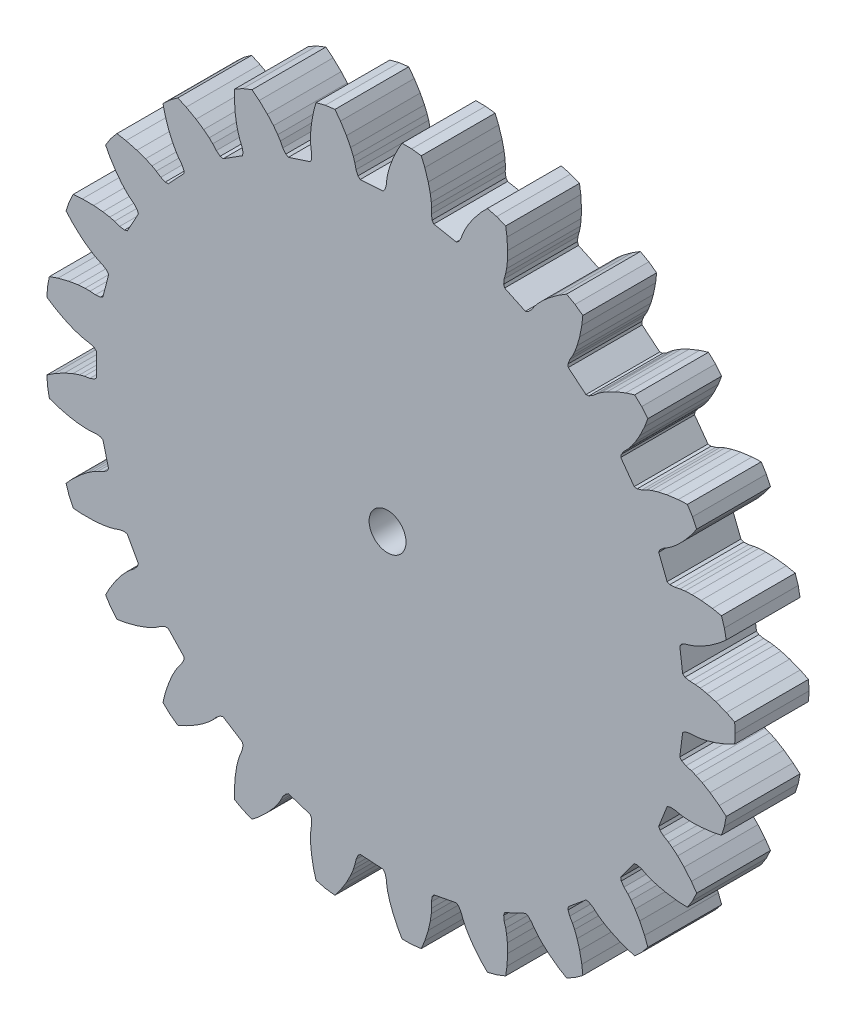
from build123d import *

# Parameters (mm, degrees)
MODEL_R             = 1.5875
BOSS_EXTRUDE1_DEPTH = 6.35


with BuildPart() as part:
    # Model → Boss-Extrude1 (new body)
    with BuildSketch(Plane.XY):
        Polygon((28.724078901, -8.263137844), (28.98062214, -7.473578941), (29.136184489, -6.658092552), (28.534273156, -6.144343716), (27.744510482, -5.577223626), (27.066883431, -5.171965759), (26.521840963, -4.905167788), (26.126650882, -4.751234836), (25.675747676, -4.617827678), (25.303834334, -4.430734433), (25.141153364, -4.229322014), (25.388043562, -2.274984866), (25.595702841, -2.1203573), (26.00246004, -2.03163302), (26.472374303, -2.014552161), (26.89343033, -1.963735072), (27.487699244, -1.8408656), (28.244820928, -1.616858649), (29.150808787, -1.26396167), (29.861574108, -0.91604246), (29.913702255, -0.087489292), (29.861574108, 0.741063875), (29.150808787, 1.088983086), (28.244820928, 1.441880065), (27.487699244, 1.665887016), (26.89343033, 1.788756487), (26.472374303, 1.839573576), (26.00246004, 1.856654436), (25.595702841, 1.945378715), (25.388043562, 2.100006281), (25.141153364, 4.054343429), (25.303834334, 4.255755849), (25.675747676, 4.442849093), (26.126650882, 4.576256252), (26.521840963, 4.730189204), (27.066883431, 4.996987175), (27.744510482, 5.402245041), (28.534273156, 5.969365131), (29.136184489, 6.483113968), (28.98062214, 7.298600357), (28.724078901, 8.08815926), (27.94911959, 8.248387801), (26.983833096, 8.364887854), (26.194789519, 8.393568708), (25.58863426, 8.364789341), (25.168168787, 8.309297541), (24.708769907, 8.208978849), (24.292726903, 8.193759291), (24.05313731, 8.291886184), (23.327979737, 10.123425142), (23.435460553, 10.358966931), (23.749161356, 10.632673385), (24.152721597, 10.87402438), (24.497214486, 11.121401022), (24.958783486, 11.515363594), (25.514338104, 12.076408534), (26.1382519, 12.822117494), (26.593488941, 13.469415227), (26.240010652, 14.220594829), (25.795171876, 14.921548578), (25.004712119, 14.884018701), (24.04077949, 14.756801701), (23.26939253, 14.588354336), (22.689437891, 14.409734442), (22.295982363, 14.251420509), (21.875964588, 14.040005657), (21.47677729, 13.921798561), (21.220311678, 13.957259109), (20.062451048, 15.550917547), (20.107978295, 15.80578875), (20.343755583, 16.14891043), (20.674615685, 16.48304029), (20.946765628, 16.808317037), (21.295859082, 17.304690093), (21.694433726, 17.98626959), (22.113295846, 18.863711784), (22.393254378, 19.603886317), (21.864070489, 20.243559754), (21.258887033, 20.811864847), (20.502594323, 20.578934693), (19.600582992, 20.215994152), (18.895321727, 19.861002734), (18.378008391, 19.543765659), (18.036285066, 19.292577038), (17.682039658, 18.98335), (17.324790472, 18.769582753), (17.067563519, 18.740148839), (15.549752473, 19.995791337), (15.530465507, 20.253977459), (15.673504526, 20.644954767), (15.910875333, 21.050868884), (16.093582147, 21.433607403), (16.308265228, 22.001201998), (16.524815989, 22.760489906), (16.712307786, 23.714532412), (16.799396985, 24.501075857), (16.127758066, 24.989050095), (15.400255831, 25.388997833), (14.725650822, 24.975303259), (13.942237477, 24.399444067), (13.347416067, 23.880214013), (12.925248733, 23.444292929), (12.656729345, 23.116012725), (12.390514844, 22.728403372), (12.097651051, 22.432507757), (11.855825273, 22.340028821), (10.07343346, 23.178758744), (9.990544153, 23.424037), (10.031857235, 23.838303395), (10.160823866, 24.290496693), (10.24260741, 24.706648115), (10.309390792, 25.309800193), (10.330310989, 26.099087659), (10.274651662, 27.069784479), (10.163399393, 27.853275419), (9.391506988, 28.158889242), (8.587397616, 28.365349437), (8.03686822, 27.796884396), (7.421277603, 27.044289903), (6.974270866, 26.393446346), (6.67377586, 25.866231778), (6.495332469, 25.481487044), (6.333876113, 25.039850298), (6.123799422, 24.680418524), (5.912569621, 24.530705358), (3.977591275, 24.899822219), (3.836307865, 25.116780876), (3.773299159, 25.528306475), (3.785758165, 25.998365986), (3.761479679, 26.421781986), (3.676167116, 27.022593285), (3.500142255, 27.792286475), (3.204829086, 28.718645158), (2.902225738, 29.449853974), (2.078580685, 29.553904542), (1.248389324, 29.553904542), (0.856527329, 28.866387782), (0.447439263, 27.984346268), (0.176334275, 27.242784103), (0.016392804, 26.657402881), (-0.060762335, 26.240368544), (-0.107315651, 25.772454065), (-0.221405349, 25.372070552), (-0.388766826, 25.174530186), (-2.3547499, 25.050841015), (-2.545550056, 25.225847761), (-2.708921483, 25.6087749), (-2.813752946, 26.067165056), (-2.942567956, 26.471240849), (-3.174615962, 27.031960184), (-3.536525591, 27.733696444), (-4.05293699, 28.557510468), (-4.527877735, 29.190492622), (-5.351522788, 29.086442054), (-6.155632161, 28.879981859), (-6.364204625, 28.116612586), (-6.541085632, 27.160545963), (-6.619254348, 26.374860269), (-6.628592573, 25.768094048), (-6.59961152, 25.344973908), (-6.528336678, 24.880182485), (-6.539270708, 24.464004802), (-6.652247926, 24.231049423), (-8.52570578, 23.622326066), (-8.754034006, 23.744384584), (-9.007502926, 24.07465254), (-9.223037912, 24.492571002), (-9.448295525, 24.851917021), (-9.812498545, 25.337312335), (-10.337552828, 25.926998995), (-11.04261443, 26.596505093), (-11.660050299, 27.091487989), (-12.431942705, 26.785874166), (-13.15944494, 26.385926428), (-13.171622498, 25.594669942), (-13.105182363, 24.624651393), (-12.985503178, 23.84420969), (-12.843651403, 23.254183823), (-12.710355143, 22.851564076), (-12.525730604, 22.419100262), (-12.432821941, 22.013278384), (-12.484316124, 21.759545435), (-14.147532512, 20.704036219), (-14.399042106, 20.765477124), (-14.726682135, 21.022333948), (-15.039377788, 21.373521361), (-15.34692424, 21.665558574), (-15.820398058, 22.045130693), (-16.475605904, 22.485715572), (-17.325016096, 22.958846215), (-18.046151322, 23.284728256), (-18.717790241, 22.796754018), (-19.322973697, 22.228448925), (-19.137991189, 21.459022781), (-18.832404589, 20.536002138), (-18.522397387, 19.80984245), (-18.23826868, 19.273630432), (-18.009032708, 18.916809157), (-17.722659112, 18.543846244), (-17.531745547, 18.173879452), (-17.518521128, 17.915311907), (-18.866990047, 16.479338358), (-19.125877736, 16.476301092), (-19.507102045, 16.643607524), (-19.897310548, 16.905997492), (-20.267821564, 17.112376127), (-20.820816079, 17.36227514), (-21.56500837, 17.626074669), (-22.505395584, 17.873101318), (-23.284918589, 18.009406138), (-23.814102478, 17.369732701), (-24.258941254, 16.668778952), (-23.888421811, 15.969529024), (-23.362889876, 15.151503069), (-22.88203355, 14.525252678), (-22.473480762, 14.076546684), (-22.162708816, 13.787944273), (-21.792580069, 13.497916893), (-21.515657406, 13.187051561), (-21.438545322, 12.93989617), (-22.38753751, 11.213685788), (-22.637536429, 11.146361192), (-23.048391294, 11.213604755), (-23.49159441, 11.370710352), (-23.901789421, 11.478462879), (-24.499557953, 11.582986711), (-25.28597435, 11.653425397), (-26.2582506, 11.658826459), (-27.047181087, 11.596989524), (-27.400659376, 10.845809922), (-27.657202615, 10.056251019), (-27.124427336, 9.471113753), (-26.411971171, 8.809482064), (-25.790479691, 8.322490587), (-25.283173697, 7.989484463), (-24.910392723, 7.787234868), (-24.479765374, 7.598366508), (-24.134233681, 7.366135447), (-23.998079169, 7.145921893), (-24.487965958, 5.237938824), (-24.713367755, 5.110557152), (-25.128037652, 5.073512685), (-25.596387301, 5.115462387), (-26.020492245, 5.117818319), (-26.6254748, 5.070399355), (-27.404701868, 4.943051274), (-28.347775462, 4.706487381), (-29.096542026, 4.450394134), (-29.252104374, 3.634907745), (-29.304232521, 2.806354577), (-28.642677636, 2.372096298), (-27.788063482, 1.908431629), (-27.064987444, 1.591298531), (-26.490804146, 1.394916277), (-26.079437342, 1.291727582), (-25.615369292, 1.215885536), (-25.222939596, 1.076880679), (-25.036297745, 0.897445789), (-25.036297745, -1.072424374), (-25.222939596, -1.251859264), (-25.615369292, -1.390864121), (-26.079437342, -1.466706167), (-26.490804146, -1.569894861), (-27.064987444, -1.766277115), (-27.788063482, -2.083410213), (-28.642677636, -2.547074882), (-29.304232521, -2.981333162), (-29.252104374, -3.809886329), (-29.096542026, -4.625372718), (-28.347775462, -4.881465966), (-27.404701868, -5.118029859), (-26.6254748, -5.245377939), (-26.020492245, -5.292796904), (-25.596387301, -5.290440971), (-25.128037652, -5.248491269), (-24.713367755, -5.285535736), (-24.487965958, -5.412917409), (-23.998079169, -7.320900478), (-24.134233681, -7.541114032), (-24.479765374, -7.773345093), (-24.910392723, -7.962213452), (-25.283173697, -8.164463048), (-25.790479691, -8.497469172), (-26.411971171, -8.984460649), (-27.124427336, -9.646092337), (-27.657202615, -10.231229604), (-27.400659376, -11.020788507), (-27.047181087, -11.771968109), (-26.2582506, -11.833805044), (-25.28597435, -11.828403981), (-24.499557953, -11.757965296), (-23.901789421, -11.653441463), (-23.49159441, -11.545688936), (-23.048391294, -11.38858334), (-22.637536429, -11.321339777), (-22.38753751, -11.388664372), (-21.438545322, -13.114874755), (-21.515657406, -13.362030145), (-21.792580069, -13.672895478), (-22.162708816, -13.962922857), (-22.473480762, -14.251525268), (-22.88203355, -14.700231263), (-23.362889876, -15.326481653), (-23.888421811, -16.144507609), (-24.258941254, -16.843757536), (-23.814102478, -17.544711285), (-23.284918589, -18.184384723), (-22.505395584, -18.048079903), (-21.56500837, -17.801053254), (-20.820816079, -17.537253724), (-20.267821564, -17.287354711), (-19.897310548, -17.080976077), (-19.507102045, -16.818586109), (-19.125877736, -16.651279676), (-18.866990047, -16.654316943), (-17.518521128, -18.090290491), (-17.531745547, -18.348858036), (-17.722659112, -18.718824829), (-18.009032708, -19.091787741), (-18.23826868, -19.448609017), (-18.522397387, -19.984821034), (-18.832404589, -20.710980722), (-19.137991189, -21.634001366), (-19.322973697, -22.40342751), (-18.717790241, -22.971732603), (-18.046151322, -23.459706841), (-17.325016096, -23.1338248), (-16.475605904, -22.660694157), (-15.820398058, -22.220109278), (-15.34692424, -21.840537158), (-15.039377788, -21.548499945), (-14.726682135, -21.197312532), (-14.399042106, -20.940455708), (-14.147532512, -20.879014803), (-12.484316124, -21.934524019), (-12.432821941, -22.188256968), (-12.525730604, -22.594078846), (-12.710355143, -23.026542661), (-12.843651403, -23.429162408), (-12.985503178, -24.019188275), (-13.105182363, -24.799629977), (-13.171622498, -25.769648527), (-13.15944494, -26.560905012), (-12.431942705, -26.960852751), (-11.660050299, -27.266466574), (-11.04261443, -26.771483678), (-10.337552828, -26.10197758), (-9.812498545, -25.512290919), (-9.448295525, -25.026895606), (-9.223037912, -24.667549586), (-9.007502926, -24.249631125), (-8.754034006, -23.919363169), (-8.52570578, -23.79730465), (-6.652247926, -24.406028007), (-6.539270708, -24.638983387), (-6.528336678, -25.055161069), (-6.59961152, -25.519952493), (-6.628592573, -25.943072632), (-6.619254348, -26.549838854), (-6.541085632, -27.335524548), (-6.364204625, -28.291591171), (-6.155632161, -29.054960443), (-5.351522788, -29.261420639), (-4.527877735, -29.365471207), (-4.05293699, -28.732489052), (-3.536525591, -27.908675029), (-3.174615962, -27.206938769), (-2.942567956, -26.646219434), (-2.813752946, -26.24214364), (-2.708921483, -25.783753484), (-2.545550056, -25.400826346), (-2.3547499, -25.2258196), (-0.388766826, -25.349508771), (-0.221405349, -25.547049137), (-0.107315651, -25.947432649), (-0.060762335, -26.415347128), (0.016392804, -26.832381465), (0.176334275, -27.417762688), (0.447439263, -28.159324852), (0.856527329, -29.041366366), (1.248389324, -29.728883127), (2.078580685, -29.728883127), (2.902225738, -29.624832559), (3.204829086, -28.893623743), (3.500142255, -27.967265059), (3.676167116, -27.197571869), (3.761479679, -26.596760571), (3.785758165, -26.173344571), (3.773299159, -25.70328506), (3.836307865, -25.29175946), (3.977591275, -25.074800804), (5.912569621, -24.705683943), (6.123799422, -24.855397108), (6.333876113, -25.214828882), (6.495332469, -25.656465629), (6.67377586, -26.041210362), (6.974270866, -26.568424931), (7.421277603, -27.219268487), (8.03686822, -27.97186298), (8.587397616, -28.540328022), (9.391506988, -28.333867826), (10.163399393, -28.028254003), (10.274651662, -27.244763064), (10.330310989, -26.274066243), (10.309390792, -25.484778778), (10.24260741, -24.881626699), (10.160823866, -24.465475278), (10.031857235, -24.013281979), (9.990544153, -23.599015585), (10.07343346, -23.353737328), (11.855825273, -22.515007406), (12.097651051, -22.607486342), (12.390514844, -22.903381957), (12.656729345, -23.29099131), (12.925248733, -23.619271513), (13.347416067, -24.055192598), (13.942237477, -24.574422652), (14.725650822, -25.150281844), (15.400255831, -25.563976418), (16.127758066, -25.16402868), (16.799396985, -24.676054441), (16.712307786, -23.889510997), (16.524815989, -22.93546849), (16.308265228, -22.176180583), (16.093582147, -21.608585988), (15.910875333, -21.225847469), (15.673504526, -20.819933351), (15.530465507, -20.428956043), (15.549752473, -20.170769922), (17.067563519, -18.915127423), (17.324790472, -18.944561338), (17.682039658, -19.158328585), (18.036285066, -19.467555623), (18.378008391, -19.718744244), (18.895321727, -20.035981319), (19.600582992, -20.390972737), (20.502594323, -20.753913277), (21.258887033, -20.986843431), (21.864070489, -20.418538338), (22.393254378, -19.778864901), (22.113295846, -19.038690368), (21.694433726, -18.161248175), (21.295859082, -17.479668678), (20.946765628, -16.983295622), (20.674615685, -16.658018874), (20.343755583, -16.323889014), (20.107978295, -15.980767335), (20.062451048, -15.725896132), (21.220311678, -14.132237694), (21.47677729, -14.096777146), (21.875964588, -14.214984242), (22.295982363, -14.426399093), (22.689437891, -14.584713026), (23.26939253, -14.763332921), (24.04077949, -14.931780286), (25.004712119, -15.058997285), (25.795171876, -15.096527162), (26.240010652, -14.395573413), (26.593488941, -13.644393812), (26.1382519, -12.997096078), (25.514338104, -12.251387119), (24.958783486, -11.690342178), (24.497214486, -11.296379606), (24.152721597, -11.049002964), (23.749161356, -10.80765197), (23.435460553, -10.533945516), (23.327979737, -10.298403726), (24.05313731, -8.466864769), (24.292726903, -8.368737875), (24.708769907, -8.383957434), (25.168168787, -8.484276126), (25.58863426, -8.539767925), (26.194789519, -8.568547293), (26.983833096, -8.539866438), (27.94911959, -8.423366385), align=None)
        Circle(MODEL_R, mode=Mode.SUBTRACT)
    extrude(amount=BOSS_EXTRUDE1_DEPTH)


solid = part.part
